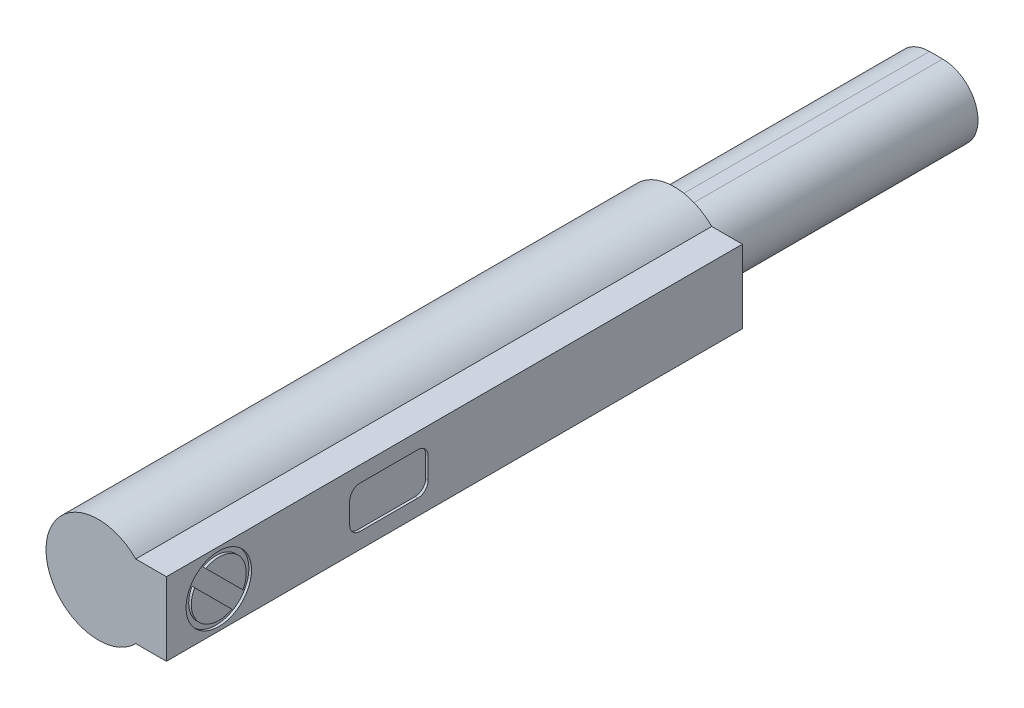
from build123d import *

# Parameters (mm, degrees)
EXTRUDE_1_DEPTH     = 22
EXTRUDE_2_DEPTH     = 10
SKETCH_3_R          = 1.25
SKETCH_3_R_2        = 1.05
CUT_EXTRUDE_1_DEPTH = 0.1
CUT_EXTRUDE_2_DEPTH = 0.1
CUT_EXTRUDE_3_DEPTH = 0.1


with BuildPart() as part:
    # 草图1 → 凸台-拉伸1 (new body)
    with BuildSketch(Plane.XY):
        with BuildLine():
            Line((1.428285686, -1.4), (2.6, -1.4))
            Line((2.6, -1.4), (2.6, 1.4))
            Line((2.6, 1.4), (1.428285686, 1.4))
            ThreePointArc((1.428285686, 1.4), (-2, 0), (1.428285686, -1.4))
        make_face()
    extrude(amount=-EXTRUDE_1_DEPTH)

    # 草图2 → 凸台-拉伸2 (add)
    with BuildSketch(Plane.XY.offset(-22)):
        with BuildLine():
            Line((-0.25, -1.35), (0.25, -1.35))
            ThreePointArc((0.25, -1.35), (1.6, 0), (0.25, 1.35))
            Line((0.25, 1.35), (-0.25, 1.35))
            ThreePointArc((-0.25, 1.35), (-1.6, 0), (-0.25, -1.35))
        make_face()
    extrude(amount=-EXTRUDE_2_DEPTH)

    # 草图3 → 切除-拉伸1 (cut)
    with BuildSketch(Plane(origin=(2.6, 0, 0), x_dir=(0, 0, -1), z_dir=(1, 0, 0))):
        with Locations((2, 0)):
            Circle(SKETCH_3_R)
        with Locations((2, 0)):
            Circle(SKETCH_3_R_2, mode=Mode.SUBTRACT)
    extrude(amount=-CUT_EXTRUDE_1_DEPTH, mode=Mode.SUBTRACT)

    # 草图4 → 切除-拉伸2 (cut)
    with BuildSketch(Plane(origin=(2.6, 0, 0), x_dir=(0, 0, -1), z_dir=(1, 0, 0))):
        with BuildLine():
            Line((7.4, -0.8), (9.6, -0.8))
            ThreePointArc((9.6, -0.8), (9.882842712, -0.682842712), (10, -0.4))
            Line((10, -0.4), (10, 0.4))
            ThreePointArc((10, 0.4), (9.882842712, 0.682842712), (9.6, 0.8))
            Line((9.6, 0.8), (7.4, 0.8))
            ThreePointArc((7.4, 0.8), (7.117157288, 0.682842712), (7, 0.4))
            Line((7, 0.4), (7, -0.4))
            ThreePointArc((7, -0.4), (7.117157288, -0.682842712), (7.4, -0.8))
        make_face()
    extrude(amount=-CUT_EXTRUDE_2_DEPTH, mode=Mode.SUBTRACT)

    # 草图5 → 切除-拉伸3 (cut)
    with BuildSketch(Plane(origin=(2.6, 0, 0), x_dir=(0, 0, -1), z_dir=(1, 0, 0))):
        with BuildLine():
            Line((0.966284129, 0.609451802), (2.609451802, -1.033715871))
            ThreePointArc((2.609451802, -1.033715871), (2.848528137, -0.848528137), (3.033715871, -0.609451802))
            Line((3.033715871, -0.609451802), (1.390548198, 1.033715871))
            ThreePointArc((1.390548198, 1.033715871), (1.151471863, 0.848528137), (0.966284129, 0.609451802))
        make_face()
    extrude(amount=-CUT_EXTRUDE_3_DEPTH, mode=Mode.SUBTRACT)


solid = part.part
